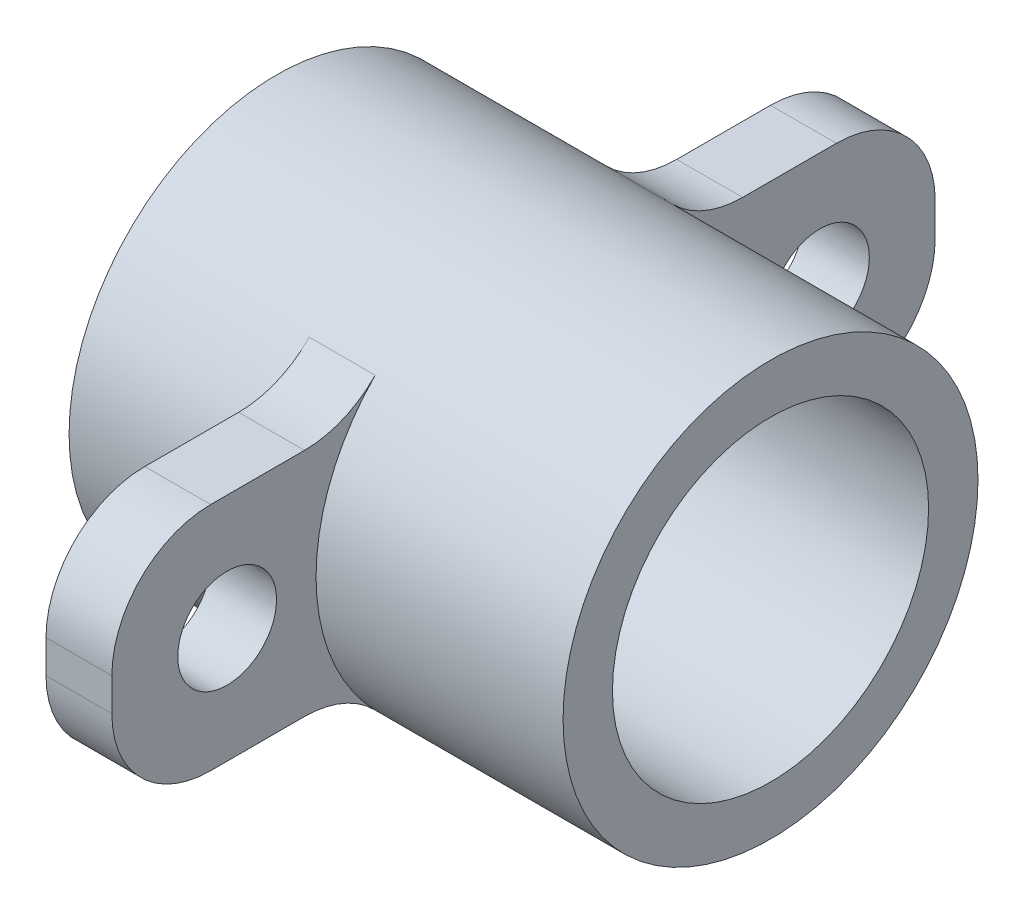
from build123d import *

# Parameters (mm, degrees)
SKETCH1_R           = 6.3
BOSS_EXTRUDE1_DEPTH = 7.5
SKETCH26_R          = 1.5
BOSS_EXTRUDE3_DEPTH = 2
FILLET1_R           = 3
SKETCH24_R          = 4.8
CUT_EXTRUDE1_DEPTH  = 16


with BuildPart() as part:
    # Sketch1 → Boss-Extrude1 (new body, symmetric)
    with BuildSketch(Plane(origin=(0, 0, 0), x_dir=(0, 0, -1), z_dir=(1, 0, 0))):
        Circle(SKETCH1_R)
    extrude(amount=BOSS_EXTRUDE1_DEPTH, both=True)

    # Sketch26 → Boss-Extrude3 (add)
    with BuildSketch(Plane(origin=(0, 0, 0), x_dir=(0, 0, -1), z_dir=(1, 0, 0))):
        with BuildLine():
            Line((5.238320341, 3.5), (12.5, 3.5))
            Line((12.5, 3.5), (12.5, -3.5))
            Line((12.5, -3.5), (5.238320341, -3.5))
            ThreePointArc((5.238320341, -3.5), (6.3, 0), (5.238320341, 3.5))
        make_face()
        with Locations((9, 0)):
            Circle(SKETCH26_R, mode=Mode.SUBTRACT)
        with BuildLine():
            Line((-5.238320341, -3.5), (-12.5, -3.5))
            Line((-12.5, -3.5), (-12.5, 3.5))
            Line((-12.5, 3.5), (-5.238320341, 3.5))
            ThreePointArc((-5.238320341, 3.5), (-6.3, 0), (-5.238320341, -3.5))
        make_face()
        with Locations((-9, 0)):
            Circle(SKETCH26_R, mode=Mode.SUBTRACT)
    extrude(amount=-BOSS_EXTRUDE3_DEPTH)

    # Fillet1
    fillet1_edges = [part.edges().sort_by_distance(p)[0] for p in [
        (-1, -3.5, 12.5),
        (-1, 3.5, 12.5),
        (-1, 3.5, 5.238320341),
        (-1, -3.5, 5.238320341),
        (-1, -3.5, -5.238320341),
        (-1, 3.5, -5.238320341),
        (-1, 3.5, -12.5),
        (-1, -3.5, -12.5),
    ]]
    fillet(fillet1_edges, radius=FILLET1_R)

    # Sketch24 → Cut-Extrude1 (cut, through all)
    with BuildSketch(Plane.ZY.offset(7.5)):
        Circle(SKETCH24_R)
    extrude(amount=-CUT_EXTRUDE1_DEPTH, mode=Mode.SUBTRACT)


solid = part.part
